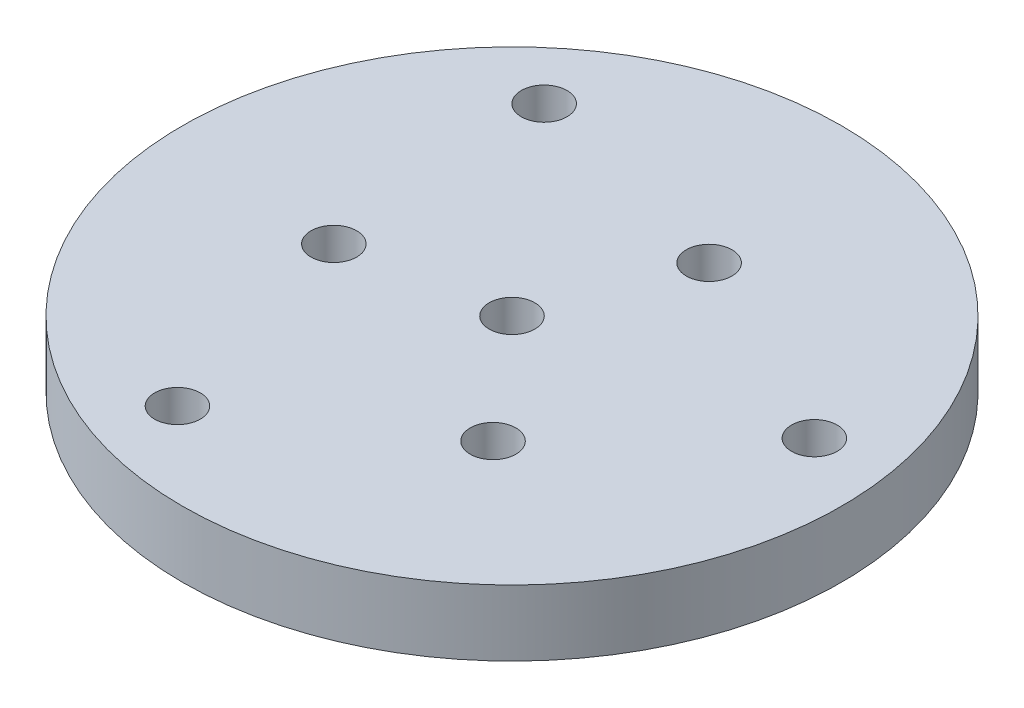
from build123d import *

# Parameters (mm, degrees)
SKETCH1_R           = 47.625
SKETCH1_R_2         = 3.3
BOSS_EXTRUDE1_DEPTH = 4.7625
SKETCH4_R           = 3.3
CUT_EXTRUDE2_DEPTH  = 10.525


with BuildPart() as part:
    # Sketch1 → Boss-Extrude1 (new body, symmetric)
    with BuildSketch(Plane(origin=(0, 0, 0), x_dir=(1, 0, 0), z_dir=(0, 1, 0))):
        Circle(SKETCH1_R)
        Circle(SKETCH1_R_2, mode=Mode.SUBTRACT)
    extrude(amount=BOSS_EXTRUDE1_DEPTH, both=True)

    # Sketch4 → Cut-Extrude2 (cut, through all)
    with BuildSketch(Plane(origin=(0, 4.7625, 0), x_dir=(1, 0, 0), z_dir=(0, 1, 0))):
        with Locations((-12.900657786, -35.444265963)):
            Circle(SKETCH4_R)
        with Locations((-24.24530585, 28.89443035)):
            Circle(SKETCH4_R)
        with Locations((37.145963636, 6.549835613)):
            Circle(SKETCH4_R)
        with Locations((14.285954625, -17.025337748)):
            Circle(SKETCH4_R)
        with Locations((-21.887352311, -3.859330749)):
            Circle(SKETCH4_R)
        with Locations((7.601397685, 20.884668497)):
            Circle(SKETCH4_R)
    extrude(amount=-CUT_EXTRUDE2_DEPTH, mode=Mode.SUBTRACT)


solid = part.part
